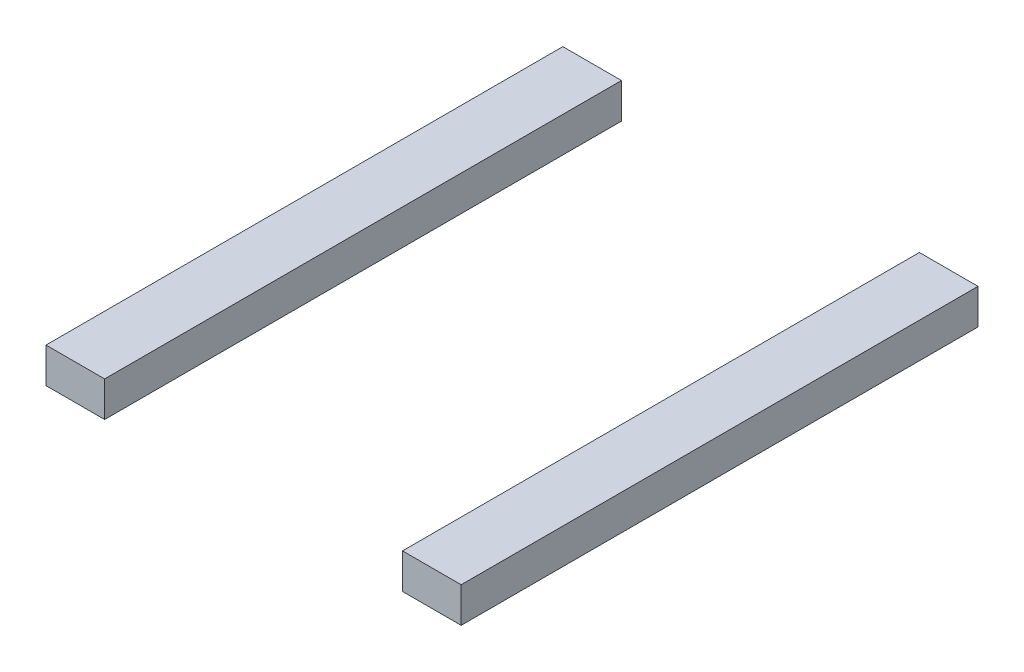
from build123d import *

# Parameters (mm, degrees)
SKETCH_1_W        = 0.5
SKETCH_1_H        = 4.407095456
EXTRUDE_1_DEPTH   = 0.3
EXTRUDE_1_2_DEPTH = 0.3


with BuildPart() as part:
    # Эскиз1 → Бобышка-Вытянуть1 (new body)
    with BuildSketch(Plane(origin=(0, 0, 0), x_dir=(1, 0, 0), z_dir=(0, 1, 0))):
        with Locations((-76.786043786, -2.203547728)):
            Rectangle(SKETCH_1_W, SKETCH_1_H)
    extrude(amount=EXTRUDE_1_DEPTH)


with BuildPart() as body_2:
    # Эскиз1 → Extrude 1 2 (new body)
    with BuildSketch(Plane(origin=(0, 0, 0), x_dir=(1, 0, 0), z_dir=(0, 1, 0))):
        with Locations((-73.746043786, -2.203547728)):
            Rectangle(SKETCH_1_W, SKETCH_1_H)
    extrude(amount=EXTRUDE_1_2_DEPTH)


solid = Compound([part.part, body_2.part])
